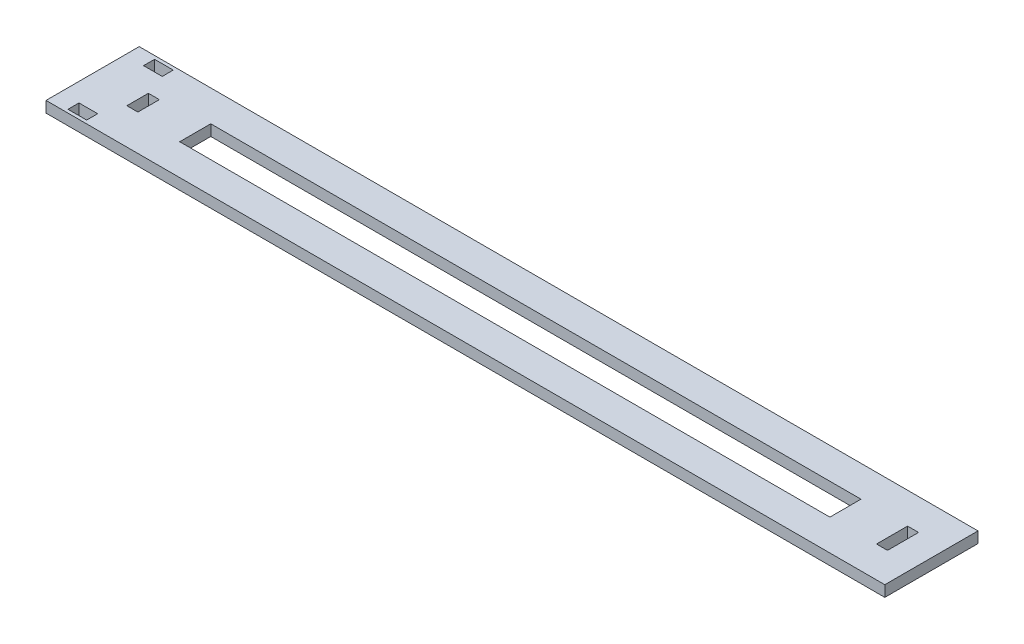
from build123d import *

# Parameters (mm, degrees)
SKETCH2_W          = 457.2
SKETCH2_H          = 50.8
BASE_DEPTH         = 6
CUT_EXTRUDE1_REACH = 8
SKETCH3_W          = 6
SKETCH3_H          = 16.933333334
SKETCH3_H_2        = 11.733333334
CUT_EXTRUDE2_REACH = 8
SKETCH4_W          = 10.18
SKETCH4_H          = 6
CUT_EXTRUDE3_REACH = 8


with BuildPart() as part:
    # Sketch2 → Base (new body)
    with BuildSketch(Plane(origin=(0, 0, 0), x_dir=(1, 0, 0), z_dir=(0, 1, 0))):
        with Locations((228.6, 25.4)):
            Rectangle(SKETCH2_W, SKETCH2_H)
    extrude(amount=BASE_DEPTH)

    # Sketch3 → Cut-Extrude1 (cut, up to next)
    with BuildSketch(Plane(origin=(0, 6, 0), x_dir=(1, 0, 0), z_dir=(0, 1, 0)), mode=Mode.PRIVATE) as cut_extrude1_sk1:
        with Locations((438.74, 25.4)):
            Rectangle(SKETCH3_W, SKETCH3_H)
    cut_extrude1_tool1 = extrude(cut_extrude1_sk1.sketch, amount=-CUT_EXTRUDE1_REACH, mode=Mode.PRIVATE) & part.part
    add(cut_extrude1_tool1.solids().sort_by_distance((438.74, 6, -25.4))[0], mode=Mode.SUBTRACT)
    # Sketch3 → Cut-Extrude1 (cut, up to next)
    with BuildSketch(Plane(origin=(0, 6, 0), x_dir=(1, 0, 0), z_dir=(0, 1, 0)), mode=Mode.PRIVATE) as cut_extrude1_sk2:
        with Locations((27.54, 25.4)):
            Rectangle(SKETCH3_W, SKETCH3_H_2)
    cut_extrude1_tool2 = extrude(cut_extrude1_sk2.sketch, amount=-CUT_EXTRUDE1_REACH, mode=Mode.PRIVATE) & part.part
    add(cut_extrude1_tool2.solids().sort_by_distance((27.54, 6, -25.4))[0], mode=Mode.SUBTRACT)

    # Sketch4 → Cut-Extrude2 (cut, up to next)
    with BuildSketch(Plane(origin=(0, 6, 0), x_dir=(1, 0, 0), z_dir=(0, 1, 0)), mode=Mode.PRIVATE) as cut_extrude2_sk1:
        with Locations((15.27, 4.8)):
            Rectangle(SKETCH4_W, SKETCH4_H)
    cut_extrude2_tool1 = extrude(cut_extrude2_sk1.sketch, amount=-CUT_EXTRUDE2_REACH, mode=Mode.PRIVATE) & part.part
    add(cut_extrude2_tool1.solids().sort_by_distance((15.27, 6, -4.8))[0], mode=Mode.SUBTRACT)
    # Sketch4 → Cut-Extrude2 (cut, up to next)
    with BuildSketch(Plane(origin=(0, 6, 0), x_dir=(1, 0, 0), z_dir=(0, 1, 0)), mode=Mode.PRIVATE) as cut_extrude2_sk2:
        with Locations((15.27, 46)):
            Rectangle(SKETCH4_W, SKETCH4_H)
    cut_extrude2_tool2 = extrude(cut_extrude2_sk2.sketch, amount=-CUT_EXTRUDE2_REACH, mode=Mode.PRIVATE) & part.part
    add(cut_extrude2_tool2.solids().sort_by_distance((15.27, 6, -46))[0], mode=Mode.SUBTRACT)

    # Sketch5 → Cut-Extrude3 (cut, up to next)
    with BuildSketch(Plane(origin=(0, 6, 0), x_dir=(1, 0, 0), z_dir=(0, 1, 0)), mode=Mode.PRIVATE) as cut_extrude3_sk1:
        Polygon((214.894666784, 33.866666667), (242.305333216, 33.866666667), (410.34, 33.866666667), (410.34, 16.933333333), (242.305333216, 16.933333333), (214.894666784, 16.933333333), (55.94, 16.933333333), (55.94, 33.866666667), align=None)
    cut_extrude3_tool1 = extrude(cut_extrude3_sk1.sketch, amount=-CUT_EXTRUDE3_REACH, mode=Mode.PRIVATE) & part.part
    add(cut_extrude3_tool1.solids().sort_by_distance((233.14, 6, -25.4))[0], mode=Mode.SUBTRACT)


solid = part.part
